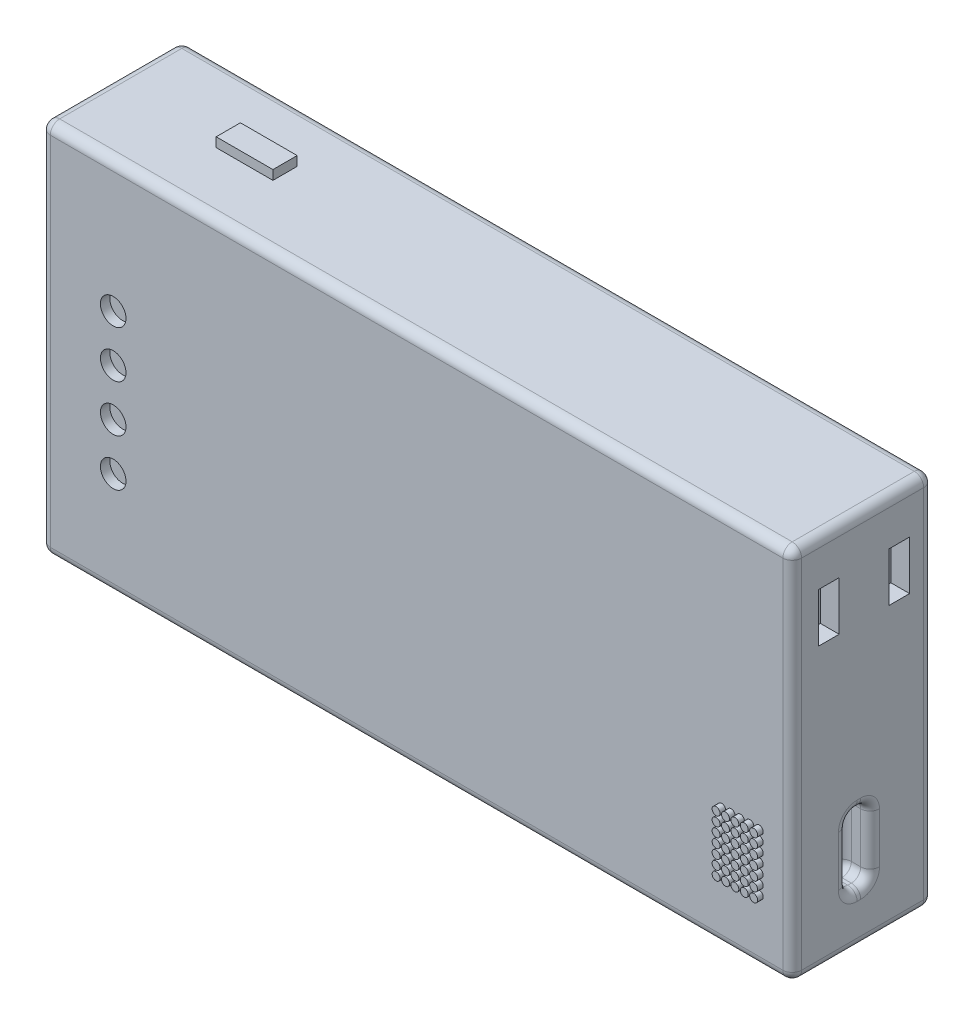
from build123d import *

# Parameters (mm, degrees)
SKETCH1_W           = 80
SKETCH1_H           = 40
BOSS_EXTRUDE1_DEPTH = 15
FILLET2_R           = 1
SKETCH2_W           = 6.044627726
SKETCH2_H           = 2.581559758
BOSS_EXTRUDE2_DEPTH = 1
SKETCH3_R           = 1.362138451
CUT_EXTRUDE1_DEPTH  = 1
SKETCH4_R           = 1.077712871
CUT_EXTRUDE2_DEPTH  = 1
SKETCH5_W           = 2.171547326
SKETCH5_H           = 5.220065687
CUT_EXTRUDE3_DEPTH  = 2
SKETCH6_W           = 2.380349953
SKETCH6_H           = 7.349852488
CUT_EXTRUDE4_DEPTH  = 3
FILLET3_R           = 1
SKETCH7_R           = 0.422381203
BOSS_EXTRUDE3_DEPTH = 0.6


with BuildPart() as part:
    # Sketch1 → Boss-Extrude1 (new body)
    with BuildSketch(Plane.XY):
        with Locations((30.786516854, -9.438202247)):
            Rectangle(SKETCH1_W, SKETCH1_H)
    extrude(amount=BOSS_EXTRUDE1_DEPTH)

    # Fillet2
    fillet2_edges = [part.edges().sort_by_distance(p)[0] for p in [
        (70.786516854, -9.438202247, 15),
        (30.786516854, 10.561797753, 15),
        (-9.213483146, -9.438202247, 15),
        (30.786516854, 10.561797753, 0),
        (70.786516854, -9.438202247, 0),
        (30.786516854, -29.438202247, 0),
        (-9.213483146, -9.438202247, 0),
        (-9.213483146, 10.561797753, 7.5),
        (70.786516854, 10.561797753, 7.5),
        (70.786516854, -29.438202247, 7.5),
        (-9.213483146, -29.438202247, 7.5),
        (30.786516854, -29.438202247, 15),
    ]]
    fillet(fillet2_edges, radius=FILLET2_R)

    # Sketch2 → Boss-Extrude2 (add)
    with BuildSketch(Plane(origin=(0, 10.561797753, 0), x_dir=(1, 0, 0), z_dir=(0, 1, 0))):
        with Locations((5.789462611, -7.027763459)):
            Rectangle(SKETCH2_W, SKETCH2_H)
    extrude(amount=BOSS_EXTRUDE2_DEPTH)

    # Sketch3 → Cut-Extrude1 (cut)
    with BuildSketch(Plane.XY.offset(15)):
        with Locations((-1.514462559, -18.319968197)):
            Circle(SKETCH3_R)
        with Locations((-1.514462559, -13.319968197)):
            Circle(SKETCH3_R)
        with Locations((-1.514462559, -8.319968197)):
            Circle(SKETCH3_R)
        with Locations((-1.514462559, -3.319968197)):
            Circle(SKETCH3_R)
    extrude(amount=-CUT_EXTRUDE1_DEPTH, mode=Mode.SUBTRACT)

    # Sketch4 → Cut-Extrude2 (cut)
    with BuildSketch(Plane.ZY.offset(9.213483146)):
        with Locations((6.831831592, 4.174602759)):
            Circle(SKETCH4_R)
    extrude(amount=-CUT_EXTRUDE2_DEPTH, mode=Mode.SUBTRACT)

    # Sketch5 → Cut-Extrude3 (cut)
    with BuildSketch(Plane(origin=(70.786516854, 0, 0), x_dir=(0, 0, -1), z_dir=(1, 0, 0))):
        with Locations((-3.591405193, 3.151469884)):
            Rectangle(SKETCH5_W, SKETCH5_H)
        with Locations((-11.091405193, 3.151469884)):
            Rectangle(SKETCH5_W, SKETCH5_H)
    extrude(amount=-CUT_EXTRUDE3_DEPTH, mode=Mode.SUBTRACT)

    # Sketch6 → Cut-Extrude4 (cut)
    with BuildSketch(Plane(origin=(70.786516854, 0, 0), x_dir=(0, 0, -1), z_dir=(1, 0, 0))):
        with Locations((-7.896724993, -20.380586234)):
            Rectangle(SKETCH6_W, SKETCH6_H)
    extrude(amount=-CUT_EXTRUDE4_DEPTH, mode=Mode.SUBTRACT)

    # Fillet3
    fillet3_edges = [part.edges().sort_by_distance(p)[0] for p in [
        (67.786516854, -20.380586234, 9.086899969),
        (69.286516854, -24.055512478, 9.086899969),
        (67.786516854, -16.70565999, 7.896724992),
        (69.286516854, -16.70565999, 9.086899969),
        (67.786516854, -20.380586234, 6.706550016),
        (69.286516854, -16.70565999, 6.706550016),
        (67.786516854, -24.055512478, 7.896724992),
        (69.286516854, -24.055512478, 6.706550016),
        (70.786516854, -20.380586234, 9.086899969),
        (70.786516854, -24.055512478, 7.896724992),
        (70.786516854, -20.380586234, 6.706550016),
        (70.786516854, -16.70565999, 7.896724992),
    ]]
    fillet(fillet3_edges, radius=FILLET3_R)

    # Sketch7 → Boss-Extrude3 (add)
    with BuildSketch(Plane.XY.offset(15)):
        with Locations((63.276390883, -22.727509248)):
            Circle(SKETCH7_R)
        with Locations((64.276390883, -22.727509248)):
            Circle(SKETCH7_R)
        with Locations((65.276390883, -22.727509248)):
            Circle(SKETCH7_R)
        with Locations((66.276390883, -22.727509248)):
            Circle(SKETCH7_R)
        with Locations((67.276390883, -22.727509248)):
            Circle(SKETCH7_R)
        with Locations((64.276390883, -21.727509248)):
            Circle(SKETCH7_R)
        with Locations((65.276390883, -21.727509248)):
            Circle(SKETCH7_R)
        with Locations((66.276390883, -21.727509248)):
            Circle(SKETCH7_R)
        with Locations((67.276390883, -21.727509248)):
            Circle(SKETCH7_R)
        with Locations((64.276390883, -20.727509248)):
            Circle(SKETCH7_R)
        with Locations((65.276390883, -20.727509248)):
            Circle(SKETCH7_R)
        with Locations((66.276390883, -20.727509248)):
            Circle(SKETCH7_R)
        with Locations((67.276390883, -20.727509248)):
            Circle(SKETCH7_R)
        with Locations((64.276390883, -19.727509248)):
            Circle(SKETCH7_R)
        with Locations((65.276390883, -19.727509248)):
            Circle(SKETCH7_R)
        with Locations((66.276390883, -19.727509248)):
            Circle(SKETCH7_R)
        with Locations((67.276390883, -19.727509248)):
            Circle(SKETCH7_R)
        with Locations((64.276390883, -18.727509248)):
            Circle(SKETCH7_R)
        with Locations((65.276390883, -18.727509248)):
            Circle(SKETCH7_R)
        with Locations((66.276390883, -18.727509248)):
            Circle(SKETCH7_R)
        with Locations((67.276390883, -18.727509248)):
            Circle(SKETCH7_R)
        with Locations((64.276390883, -17.727509248)):
            Circle(SKETCH7_R)
        with Locations((65.276390883, -17.727509248)):
            Circle(SKETCH7_R)
        with Locations((66.276390883, -17.727509248)):
            Circle(SKETCH7_R)
        with Locations((67.276390883, -17.727509248)):
            Circle(SKETCH7_R)
        with Locations((64.276390883, -16.727509248)):
            Circle(SKETCH7_R)
        with Locations((65.276390883, -16.727509248)):
            Circle(SKETCH7_R)
        with Locations((66.276390883, -16.727509248)):
            Circle(SKETCH7_R)
        with Locations((67.276390883, -16.727509248)):
            Circle(SKETCH7_R)
        with Locations((63.276390883, -21.727509248)):
            Circle(SKETCH7_R)
        with Locations((63.276390883, -20.727509248)):
            Circle(SKETCH7_R)
        with Locations((63.276390883, -19.727509248)):
            Circle(SKETCH7_R)
        with Locations((63.276390883, -18.727509248)):
            Circle(SKETCH7_R)
        with Locations((63.276390883, -17.727509248)):
            Circle(SKETCH7_R)
        with Locations((63.276390883, -16.727509248)):
            Circle(SKETCH7_R)
    extrude(amount=BOSS_EXTRUDE3_DEPTH)


solid = part.part
